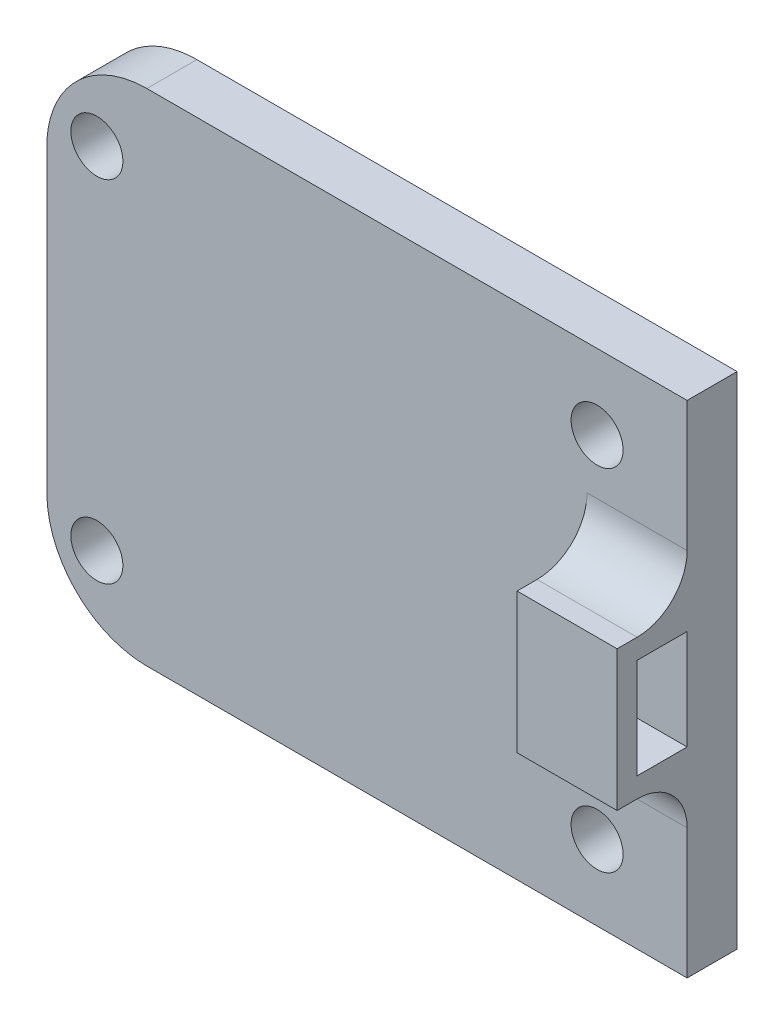
from build123d import *

# Parameters (mm, degrees)
SKETCH1_W           = 64
SKETCH1_H           = 50
SKETCH1_R           = 2.6
BOSS_EXTRUDE1_DEPTH = 5
FILLET1_R           = 10
BOSS_EXTRUDE2_DEPTH = 10
FILLET2_R           = 5


with BuildPart() as part:
    # Sketch1 → Boss-Extrude1 (new body)
    with BuildSketch(Plane.XY):
        with Locations((32, 25)):
            Rectangle(SKETCH1_W, SKETCH1_H)
        with Locations((5, 42.5)):
            Circle(SKETCH1_R, mode=Mode.SUBTRACT)
        with Locations((55, 42.5)):
            Circle(SKETCH1_R, mode=Mode.SUBTRACT)
        with Locations((55, 7.5)):
            Circle(SKETCH1_R, mode=Mode.SUBTRACT)
        with Locations((5, 7.5)):
            Circle(SKETCH1_R, mode=Mode.SUBTRACT)
    extrude(amount=BOSS_EXTRUDE1_DEPTH)

    # Fillet1
    fillet1_edges = [part.edges().sort_by_distance(p)[0] for p in [
        (0, 50, 2.5),
        (0, 0, 2.5),
    ]]
    fillet(fillet1_edges, radius=FILLET1_R)

    # Sketch3 → Boss-Extrude2 (add)
    with BuildSketch(Plane(origin=(64, 0, 0), x_dir=(0, 0, -1), z_dir=(1, 0, 0))):
        Polygon((-5, 30), (-10, 30), (-10, 20), (-5, 20), (-5, 18), (-12, 18), (-12, 32), (-5, 32), align=None)
    extrude(amount=-BOSS_EXTRUDE2_DEPTH)

    # Fillet2
    fillet2_edges = [part.edges().sort_by_distance(p)[0] for p in [
        (59, 32, 5),
        (59, 18, 5),
    ]]
    fillet(fillet2_edges, radius=FILLET2_R)


solid = part.part
